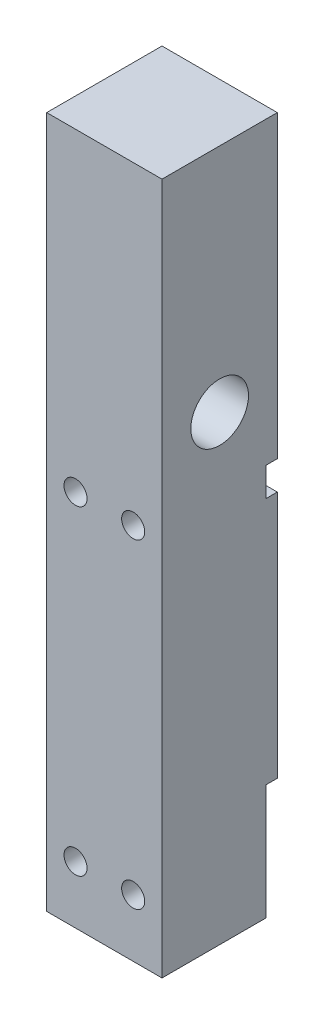
from build123d import *

# Parameters (mm, degrees)
SKETCH1_W           = 20
SKETCH1_H           = 120
SKETCH1_R           = 2.5
BOSS_EXTRUDE2_DEPTH = 20
SKETCH10_R          = 5
CUT_EXTRUDE1_DEPTH  = 10
SKETCH11_R          = 1
CUT_EXTRUDE2_DEPTH  = 124.288280059
SKETCH12_R          = 2
CUT_EXTRUDE3_DEPTH  = 5
SKETCH11_3_R        = 1
CUT_EXTRUDE4_DEPTH  = 124.288280059
SKETCH14_W          = 20
SKETCH14_H          = 5
SKETCH14_H_2        = 20
CUT_EXTRUDE6_DEPTH  = 2


with BuildPart() as part:
    # Sketch1 → Boss-Extrude2 (new body)
    with BuildSketch(Plane(origin=(0, 0, 0), x_dir=(0, 0, -1), z_dir=(1, 0, 0))):
        with Locations((10, 60)):
            Rectangle(SKETCH1_W, SKETCH1_H)
        with Locations((10, 80)):
            Circle(SKETCH1_R, mode=Mode.SUBTRACT)
    extrude(amount=-BOSS_EXTRUDE2_DEPTH)

    # Sketch10 → Cut-Extrude1 (cut)
    with BuildSketch(Plane(origin=(0, 0, 0), x_dir=(0, 0, -1), z_dir=(1, 0, 0))):
        with Locations((10, 80)):
            Circle(SKETCH10_R)
    extrude(amount=-CUT_EXTRUDE1_DEPTH, mode=Mode.SUBTRACT)

    # Sketch11 → Cut-Extrude2 (cut, through all)
    with BuildSketch(Plane.XY):
        with Locations((-15, 10)):
            Circle(SKETCH11_R)
        with Locations((-5, 10)):
            Circle(SKETCH11_R)
    extrude(amount=-CUT_EXTRUDE2_DEPTH, mode=Mode.SUBTRACT)

    # Sketch12 → Cut-Extrude3 (cut)
    with BuildSketch(Plane.XY):
        with Locations((-15, 10)):
            Circle(SKETCH12_R)
        with Locations((-5, 10)):
            Circle(SKETCH12_R)
        with Locations((-15, 65.5)):
            Circle(SKETCH12_R)
        with Locations((-5, 65.5)):
            Circle(SKETCH12_R)
    extrude(amount=-CUT_EXTRUDE3_DEPTH, mode=Mode.SUBTRACT)

    # Sketch11_3 → Cut-Extrude4 (cut, through all)
    with BuildSketch(Plane.XY):
        with Locations((-15, 65.5)):
            Circle(SKETCH11_3_R)
        with Locations((-5, 65.5)):
            Circle(SKETCH11_3_R)
    extrude(amount=-CUT_EXTRUDE4_DEPTH, mode=Mode.SUBTRACT)

    # Sketch14 → Cut-Extrude6 (cut)
    with BuildSketch(Plane(origin=(0, 0, -20), x_dir=(-1, 0, 0), z_dir=(0, 0, -1))):
        with Locations((10, 65.5)):
            Rectangle(SKETCH14_W, SKETCH14_H)
        with Locations((10, 10)):
            Rectangle(SKETCH14_W, SKETCH14_H_2)
    extrude(amount=-CUT_EXTRUDE6_DEPTH, mode=Mode.SUBTRACT)


solid = part.part
